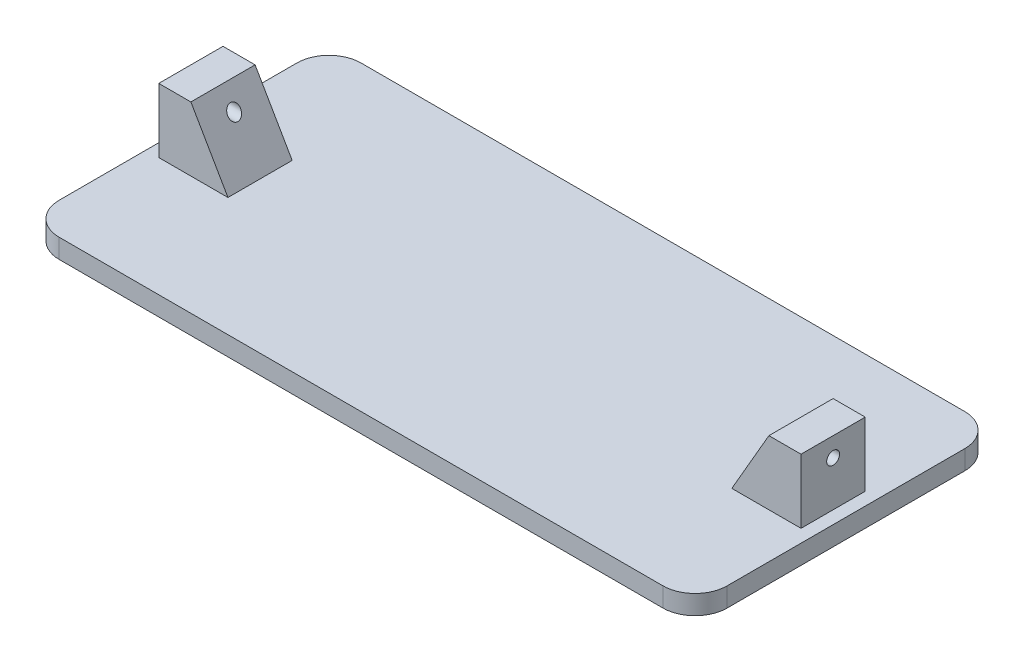
from build123d import *

# Parameters (mm, degrees)
EXTRUDE_1_DEPTH     = 3
EXTRUDE_2_DEPTH     = 5
SKETCH_4_R          = 1
CUT_EXTRUDE_1_DEPTH = 101
EXTRUDE_3_DEPTH     = 3


with BuildPart() as part:
    # Эскиз1 → Бобышка-Вытянуть1 (new body)
    with BuildSketch(Plane(origin=(0, 0, 0), x_dir=(1, 0, 0), z_dir=(0, 1, 0))):
        with BuildLine():
            Line((-45, -21.5), (45, -21.5))
            ThreePointArc((45, -21.5), (48.535533906, -20.035533906), (50, -16.5))
            Line((50, -16.5), (50, 16.5))
            ThreePointArc((50, 16.5), (48.535533906, 20.035533906), (45, 21.5))
            Line((45, 21.5), (-45, 21.5))
            ThreePointArc((-45, 21.5), (-48.535533906, 20.035533906), (-50, 16.5))
            Line((-50, 16.5), (-50, -16.5))
            ThreePointArc((-50, -16.5), (-48.535533906, -20.035533906), (-45, -21.5))
        make_face()
    extrude(amount=EXTRUDE_1_DEPTH)

    # Эскиз3 → Бобышка-Вытянуть2 (add, symmetric)
    with BuildSketch(Plane.XY):
        Polygon((-39.226497308, 3), (-45, 3), (-50, 3), (-50, 13), (-45, 13), align=None)
        Polygon((50, 3), (45, 3), (39.226497308, 3), (45, 13), (50, 13), align=None)
    extrude(amount=EXTRUDE_2_DEPTH, both=True)

    # Эскиз4 → Вырез-Вытянуть1 (cut, through all)
    with BuildSketch(Plane.ZY.offset(50)):
        with Locations((0, 10)):
            Circle(SKETCH_4_R)
    extrude(amount=-CUT_EXTRUDE_1_DEPTH, mode=Mode.SUBTRACT)

    # Эскиз5 → Бобышка-Вытянуть3 (add)
    with BuildSketch(Plane.XZ):
        with BuildLine():
            Line((52, -18.5), (52, -16.5))
            Line((52, -16.5), (52, 16.5))
            Line((52, 16.5), (52, 18.5))
            ThreePointArc((52, 18.5), (50.535533906, 22.035533906), (47, 23.5))
            Line((47, 23.5), (45, 23.5))
            Line((45, 23.5), (-45, 23.5))
            Line((-45, 23.5), (-47, 23.5))
            ThreePointArc((-47, 23.5), (-50.535533906, 22.035533906), (-52, 18.5))
            Line((-52, 18.5), (-52, 16.5))
            Line((-52, 16.5), (-52, -16.5))
            Line((-52, -16.5), (-52, -18.5))
            ThreePointArc((-52, -18.5), (-50.535533906, -22.035533906), (-47, -23.5))
            Line((-47, -23.5), (-45, -23.5))
            Line((-45, -23.5), (45, -23.5))
            Line((45, -23.5), (47, -23.5))
            ThreePointArc((47, -23.5), (50.535533906, -22.035533906), (52, -18.5))
        make_face()
        with BuildLine():
            Line((50, 16.5), (50, -16.5))
            ThreePointArc((50, -16.5), (48.535533906, -20.035533906), (45, -21.5))
            Line((45, -21.5), (-45, -21.5))
            ThreePointArc((-45, -21.5), (-48.535533906, -20.035533906), (-50, -16.5))
            Line((-50, -16.5), (-50, 16.5))
            ThreePointArc((-50, 16.5), (-48.535533906, 20.035533906), (-45, 21.5))
            Line((-45, 21.5), (45, 21.5))
            ThreePointArc((45, 21.5), (48.535533906, 20.035533906), (50, 16.5))
        make_face(mode=Mode.SUBTRACT)
    extrude(amount=-EXTRUDE_3_DEPTH)


solid = part.part
